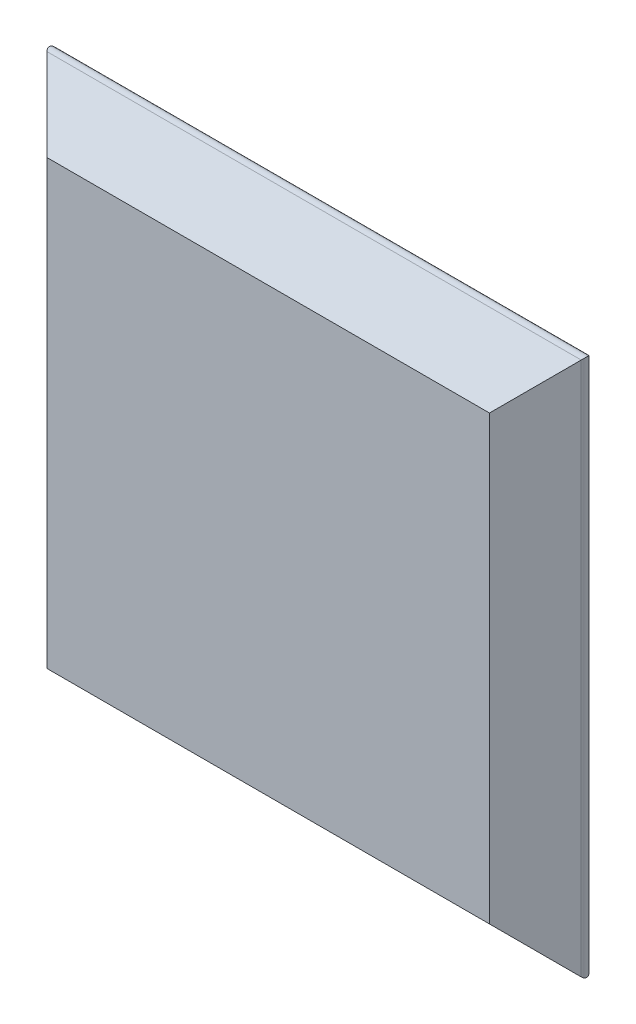
from build123d import *

# Parameters (mm, degrees)
SKETCH1_W           = 100
SKETCH1_H           = 100
BOSS_EXTRUDE1_DEPTH = 10
BOSS_EXTRUDE1_TAPER = 45
FILLET1_R           = 1


with BuildPart() as part:
    # Sketch1 → Boss-Extrude1 (new body)
    with BuildSketch(Plane.XY):
        Rectangle(SKETCH1_W, SKETCH1_H)
    extrude(amount=BOSS_EXTRUDE1_DEPTH, taper=BOSS_EXTRUDE1_TAPER)

    # Fillet1
    fillet1_edges = [part.edges().sort_by_distance(p)[0] for p in [
        (0, -50, 0),
        (-50, 0, 0),
        (0, 50, 0),
        (50, 0, 0),
    ]]
    fillet(fillet1_edges, radius=FILLET1_R)


solid = part.part
